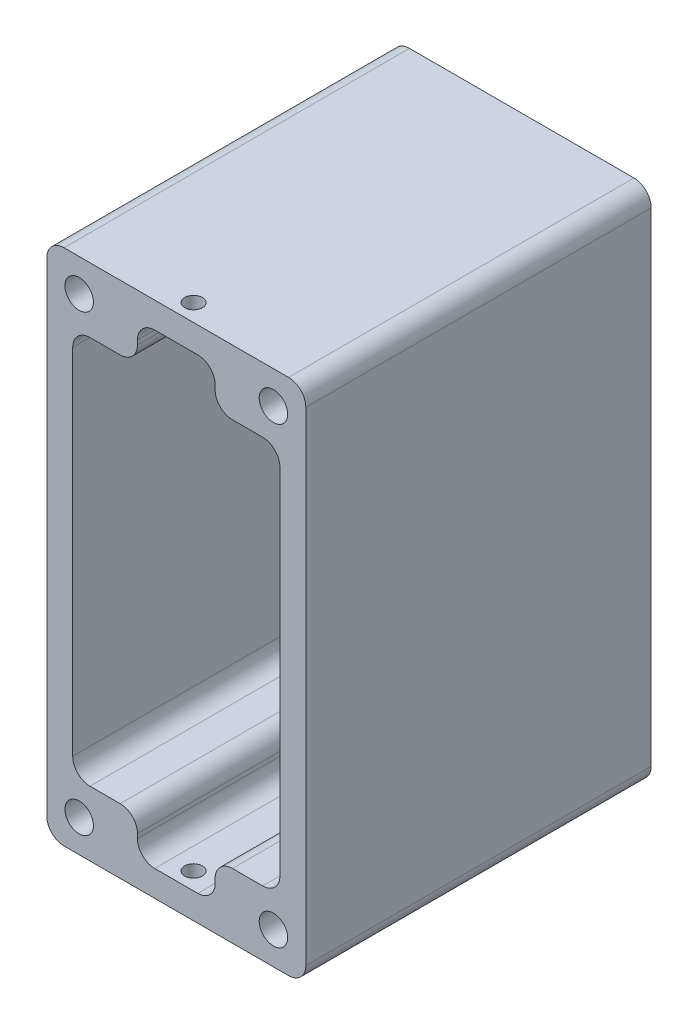
from build123d import *

# Parameters (mm, degrees)
SKETCH_1_W                  = 7.5
SKETCH_1_H                  = 7.5
EXTRUDE_1_DEPTH             = 40
FILLET_1_R                  = 2
HOLE_WIZARD_M2_5_1_D        = 2.05
HOLE_WIZARD_M4_1_AT_2_COUNT = 2
HOLE_WIZARD_M4_1_AT_2_PITCH = 22.5
HOLE_WIZARD_M4_1_AT_3_COUNT = 2
HOLE_WIZARD_M4_1_AT_3_PITCH = 57.118298294
HOLE_WIZARD_M4_1_AT_4_COUNT = 2
HOLE_WIZARD_M4_1_AT_4_PITCH = 52.5
FILLET_2_R                  = 2


with BuildPart() as part:
    # 草图1 → 凸台-拉伸1 (new body)
    with BuildSketch(Plane.XY):
        Polygon((7.5, 22.5), (4.5, 22.5), (4.5, 27), (-4.5, 27), (-4.5, 22.5), (-7.5, 22.5), (-7.5, 30), (7.5, 30), align=None)
        with Locations((-11.25, 26.25)):
            Rectangle(SKETCH_1_W, SKETCH_1_H)
        with Locations((11.25, 26.25)):
            Rectangle(SKETCH_1_W, SKETCH_1_H)
        Polygon((12, 22.5), (12, 19.5), (12, -19.5), (12, -22.5), (15, -22.5), (15, 22.5), align=None)
        Polygon((-12, 22.5), (-15, 22.5), (-15, -22.5), (-12, -22.5), (-12, -19.5), (-12, 19.5), align=None)
        with Locations((-11.25, -26.25)):
            Rectangle(SKETCH_1_W, SKETCH_1_H)
        with Locations((11.25, -26.25)):
            Rectangle(SKETCH_1_W, SKETCH_1_H)
        Polygon((7.5, -30), (-7.5, -30), (-7.5, -22.5), (-4.5, -22.5), (-4.5, -27), (4.5, -27), (4.5, -22.5), (7.5, -22.5), align=None)
    extrude(amount=EXTRUDE_1_DEPTH)

    # 圆角1
    fillet_1_edges = [part.edges().sort_by_distance(p)[0] for p in [
        (12, -22.5, 20),
        (12, 22.5, 20),
        (4.5, 22.5, 20),
        (4.5, 27, 20),
        (-4.5, 27, 20),
        (-4.5, 22.5, 20),
        (-12, 22.5, 20),
        (-12, -22.5, 20),
        (-4.5, -22.5, 20),
        (-4.5, -27, 20),
        (4.5, -27, 20),
        (4.5, -22.5, 20),
    ]]
    fillet(fillet_1_edges, radius=FILLET_1_R)

    # M2.5 螺纹孔1 (through all)
    with Locations(Plane(origin=(0, 30, 0), x_dir=(1, 0, 0), z_dir=(0, 1, 0))):
        with Locations((0, -38)):
            Hole(HOLE_WIZARD_M2_5_1_D / 2)

    # 草图14 → M4 螺纹孔1 (revolve, cut)
    with BuildSketch(Plane(origin=(11.25, 26.25, 0), x_dir=(0, 1, 0), z_dir=(1, 0, 0))):
        Polygon((0, 0), (0, 8.991420021), (1.65, 8), (1.65, 0), align=None)
    hole_wizard_m4_1 = revolve(axis=Axis((11.25, 26.25, -6.35), (0, 0, 1)), mode=Mode.SUBTRACT)

    # M4 螺纹孔1 at 2: M4 螺纹孔1 ×2
    with Locations(*[(-i * HOLE_WIZARD_M4_1_AT_2_PITCH, 0, 0) for i in range(1, HOLE_WIZARD_M4_1_AT_2_COUNT)]):
        add(hole_wizard_m4_1, mode=Mode.SUBTRACT)

    # M4 螺纹孔1 at 3: M4 螺纹孔1 ×2
    with Locations(*[Vector(-0.393919299, -0.91914503, 0) * (i * HOLE_WIZARD_M4_1_AT_3_PITCH) for i in range(1, HOLE_WIZARD_M4_1_AT_3_COUNT)]):
        add(hole_wizard_m4_1, mode=Mode.SUBTRACT)

    # M4 螺纹孔1 at 4: M4 螺纹孔1 ×2
    with Locations(*[(0, -i * HOLE_WIZARD_M4_1_AT_4_PITCH, 0) for i in range(1, HOLE_WIZARD_M4_1_AT_4_COUNT)]):
        add(hole_wizard_m4_1, mode=Mode.SUBTRACT)

    # 镜向1: M4 螺纹孔1 across plane
    add(hole_wizard_m4_1.mirror(Plane(origin=(0, 0, 20), x_dir=(1, 0, 0), z_dir=(0, 0, -1))), mode=Mode.SUBTRACT)

    # 镜向1 copy 1 sketch → 镜向1 copy 1 (revolve, cut)
    with BuildSketch(Plane(origin=(-11.25, 26.25, 40), x_dir=(0, 1, 0), z_dir=(1, 0, 0))):
        Polygon((0, 0), (0, -8.991420021), (1.65, -8), (1.65, 0), align=None)
    revolve(axis=Axis((-11.25, 26.25, 46.35), (0, 0, 1)), mode=Mode.SUBTRACT)

    # 镜向1 copy 2 sketch → 镜向1 copy 2 (revolve, cut)
    with BuildSketch(Plane(origin=(-11.25, -26.25, 40), x_dir=(0, 1, 0), z_dir=(1, 0, 0))):
        Polygon((0, 0), (0, -8.991420021), (1.65, -8), (1.65, 0), align=None)
    revolve(axis=Axis((-11.25, -26.25, 46.35), (0, 0, 1)), mode=Mode.SUBTRACT)

    # 镜向1 copy 3 sketch → 镜向1 copy 3 (revolve, cut)
    with BuildSketch(Plane(origin=(11.25, -26.25, 40), x_dir=(0, 1, 0), z_dir=(1, 0, 0))):
        Polygon((0, 0), (0, -8.991420021), (1.65, -8), (1.65, 0), align=None)
    revolve(axis=Axis((11.25, -26.25, 46.35), (0, 0, 1)), mode=Mode.SUBTRACT)

    # 圆角2
    fillet_2_edges = [part.edges().sort_by_distance(p)[0] for p in [
        (-15, -30, 20),
        (-15, 30, 20),
        (15, 30, 20),
        (15, -30, 20),
    ]]
    fillet(fillet_2_edges, radius=FILLET_2_R)


solid = part.part
